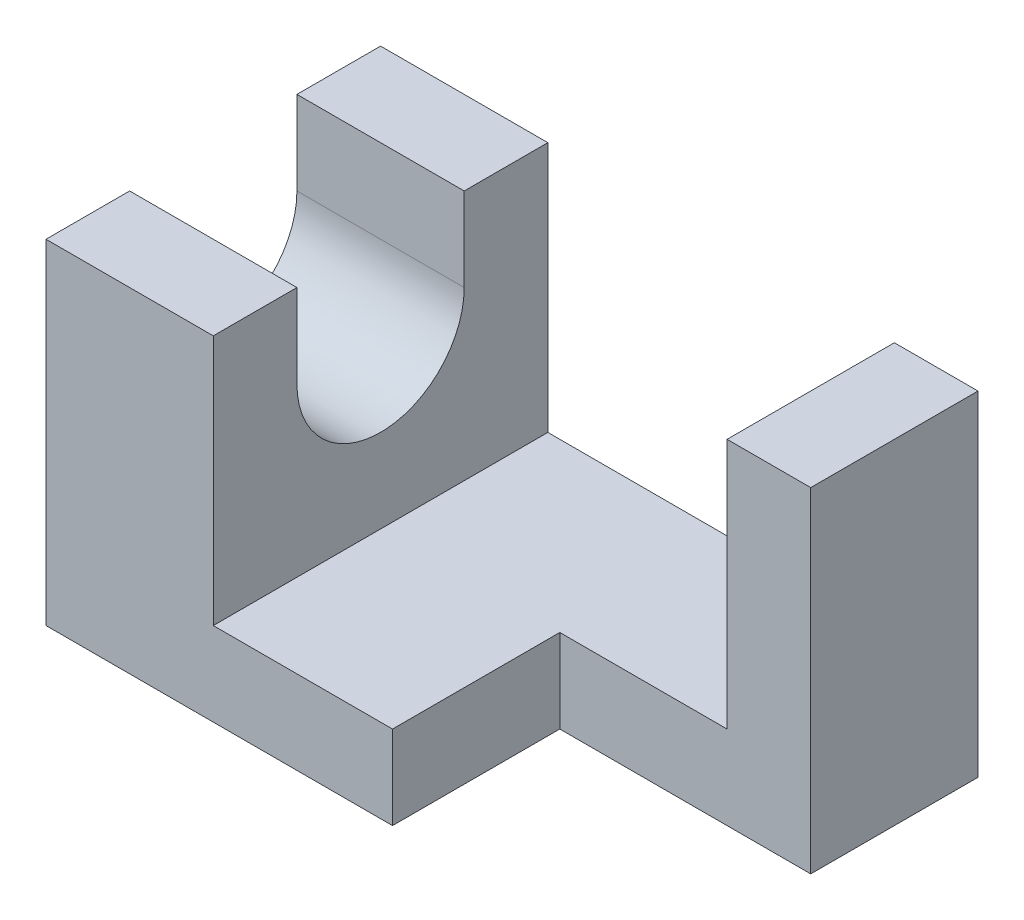
from build123d import *

# Parameters (mm, degrees)
BOSS_EXTRUDE1_DEPTH     = 7
SKETCH1_3_W             = 14
SKETCH1_3_H             = 28
SKETCH1_3_W_2           = 7
SKETCH1_3_H_2           = 14
BOSS_EXTRUDE2_DEPTH     = 28
CUT_EXTRUDE1_DEPTH      = 64.780874876
CUT_EXTRUDE1_DEPTH_BACK = 28


with BuildPart() as part:
    # Sketch1 → Boss-Extrude1 (new body)
    with BuildSketch(Plane(origin=(0, 0, 0), x_dir=(1, 0, 0), z_dir=(0, 1, 0))):
        Polygon((-15, 0), (0, 0), (0, 14), (14, 14), (14, 28), (-15, 28), align=None)
    extrude(amount=BOSS_EXTRUDE1_DEPTH)

    # Sketch1_3 → Boss-Extrude2 (add)
    with BuildSketch(Plane(origin=(0, 0, 0), x_dir=(1, 0, 0), z_dir=(0, 1, 0))):
        with Locations((-22, 14)):
            Rectangle(SKETCH1_3_W, SKETCH1_3_H)
        with Locations((17.5, 21)):
            Rectangle(SKETCH1_3_W_2, SKETCH1_3_H_2)
    extrude(amount=BOSS_EXTRUDE2_DEPTH)

    # Sketch2 → Cut-Extrude1 (cut, two sides: drawn at the far end of the back side and taken through both)
    with BuildSketch(Plane.ZY.offset(29).offset(-CUT_EXTRUDE1_DEPTH_BACK)):
        with BuildLine():
            Line((-7, 28), (-21, 28))
            Line((-21, 28), (-21, 21))
            ThreePointArc((-21, 21), (-14, 14), (-7, 21))
            Line((-7, 21), (-7, 28))
        make_face()
    extrude(amount=CUT_EXTRUDE1_DEPTH + CUT_EXTRUDE1_DEPTH_BACK, mode=Mode.SUBTRACT)


solid = part.part
